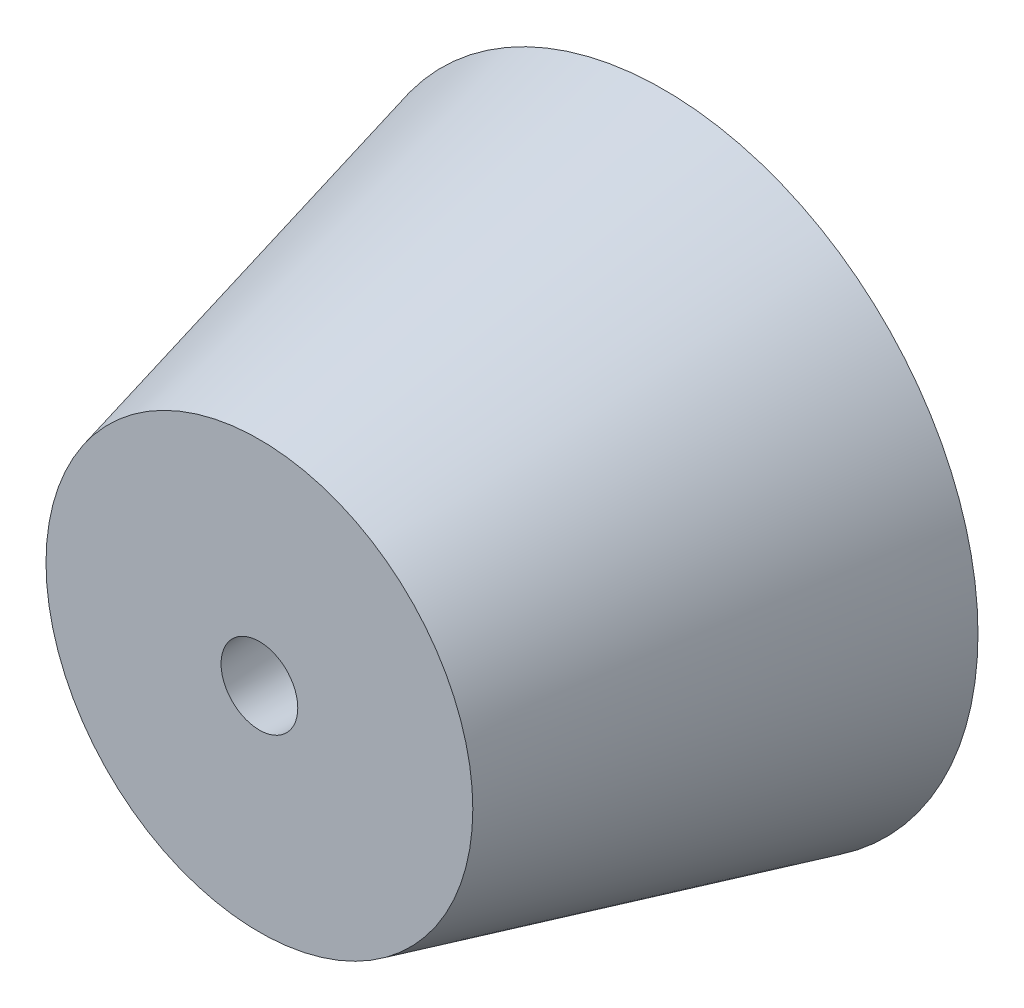
from build123d import *

# Parameters (mm, degrees)
CROQUIS1_R              = 7.770999089
SALIENTE_EXTRUIR1_DEPTH = 10
SALIENTE_EXTRUIR1_TAPER = 14
CROQUIS2_R              = 1.472990059
CORTAR_EXTRUIR1_DEPTH   = 13.836066171
CORTAR_EXTRUIR1_TAPER   = 3


with BuildPart() as part:
    # Croquis1 → Saliente-Extruir1 (new body)
    with BuildSketch(Plane.XY):
        with Locations((0, 74.800471215)):
            Circle(CROQUIS1_R)
    extrude(amount=SALIENTE_EXTRUIR1_DEPTH, taper=SALIENTE_EXTRUIR1_TAPER)

    # Croquis2 → Cortar-Extruir1 (cut)
    with BuildSketch(Plane(origin=(0, 0, 0), x_dir=(-1, 0, 0), z_dir=(0, 0, -1))):
        with Locations((0, 74.800471215)):
            Circle(CROQUIS2_R)
    extrude(amount=-CORTAR_EXTRUIR1_DEPTH, taper=CORTAR_EXTRUIR1_TAPER, mode=Mode.SUBTRACT)


solid = part.part
